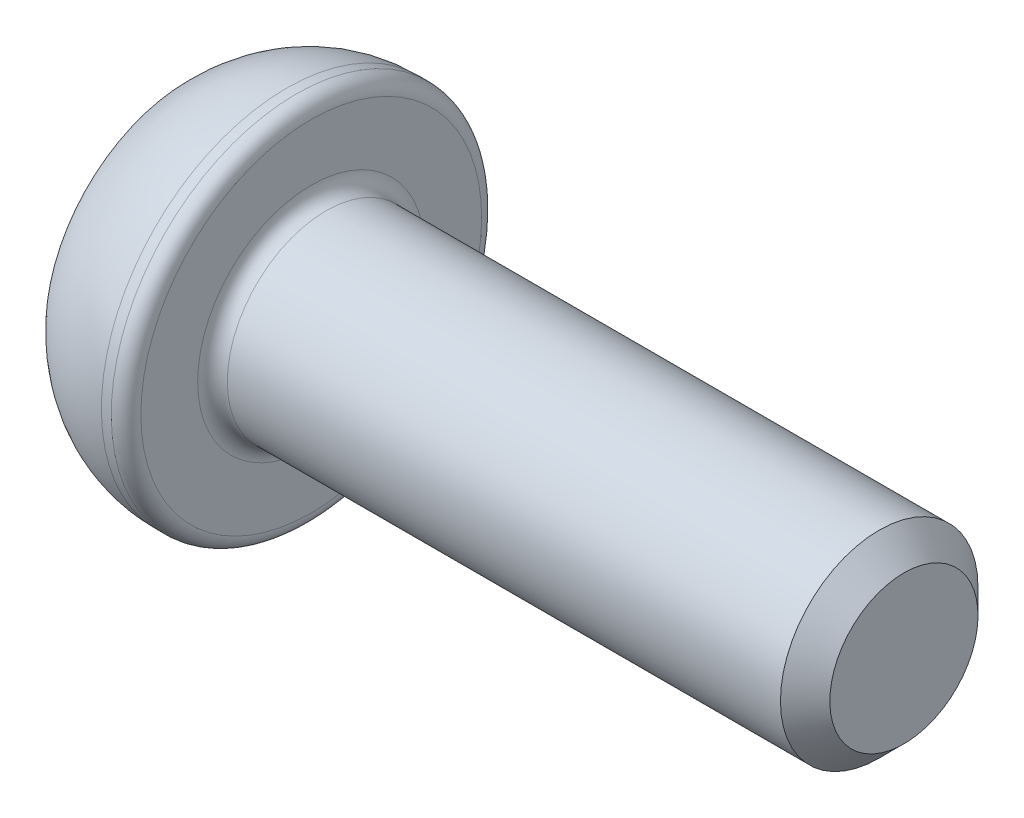
from build123d import *

# Parameters (mm, degrees)
CUT_EXTRUDE_1_DEPTH = 1.5
FILLET_1_R          = 0.3
CHAMFER_1_SIZE      = 0.5


with BuildPart() as part:
    # Эскиз1 → Повернуть1 (revolve)
    with BuildSketch(Plane.XY):
        with BuildLine():
            Line((0, 0), (0, 2.875))
            ThreePointArc((0, 2.875), (0.908484425, 3.521678457), (2, 3.75))
            Line((2, 3.75), (2.5, 3.75))
            Line((2.5, 3.75), (2.5, 2))
            Line((2.5, 2), (14.5, 2))
            Line((14.5, 2), (14.5, 0))
            Line((14.5, 0), (0, 0))
        make_face()
    revolve(axis=Axis((14.5, 0, 0), (-1, 0, 0)))

    # Эскиз2 → Вырез-Вытянуть1 (cut)
    with BuildSketch(Plane.ZY):
        Polygon((0.721687836, 1.25), (-0.721687836, 1.25), (-1.443375673, 0), (-0.721687836, -1.25), (0.721687836, -1.25), (1.443375673, 0), align=None)
    extrude(amount=-CUT_EXTRUDE_1_DEPTH, mode=Mode.SUBTRACT)

    # Скругление1
    fillet_1_edges = [part.edges().sort_by_distance(p)[0] for p in [
        (2.5, -2, 0),
        (2.5, -3.75, 0),
    ]]
    fillet(fillet_1_edges, radius=FILLET_1_R)

    # Фаска1
    chamfer_1_edges = [part.edges().sort_by_distance(p)[0] for p in [
        (14.5, -2, 0),
    ]]
    chamfer(chamfer_1_edges, length=CHAMFER_1_SIZE)


solid = part.part
